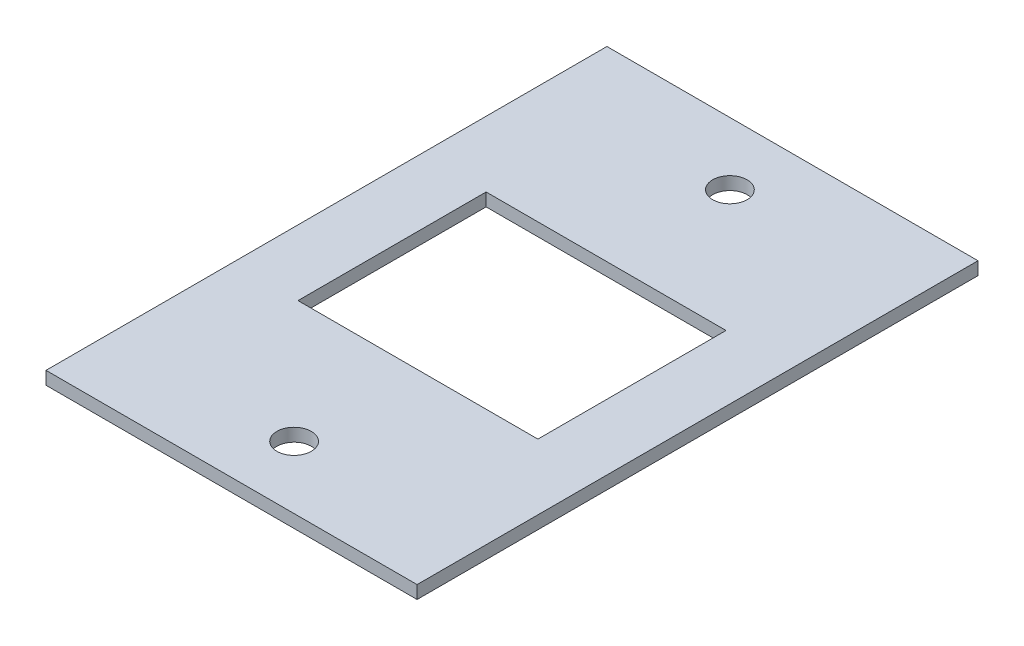
from build123d import *

# Parameters (mm, degrees)
SKETCH_1_W      = 43
SKETCH_1_H      = 65
SKETCH_1_R      = 2
SKETCH_1_W_2    = 27.8
SKETCH_1_H_2    = 21.8
EXTRUDE_1_DEPTH = 1.5


with BuildPart() as part:
    # Эскиз1 → Бобышка-Вытянуть1 (new body)
    with BuildSketch(Plane(origin=(0, 0, 0), x_dir=(1, 0, 0), z_dir=(0, 1, 0))):
        with Locations((21.5, 32.5)):
            Rectangle(SKETCH_1_W, SKETCH_1_H)
        with Locations((21.5, 7.25)):
            Circle(SKETCH_1_R, mode=Mode.SUBTRACT)
        with Locations((21.5, 57.75)):
            Circle(SKETCH_1_R, mode=Mode.SUBTRACT)
        with Locations((21.5, 32.5)):
            Rectangle(SKETCH_1_W_2, SKETCH_1_H_2, mode=Mode.SUBTRACT)
    extrude(amount=EXTRUDE_1_DEPTH)


solid = part.part
